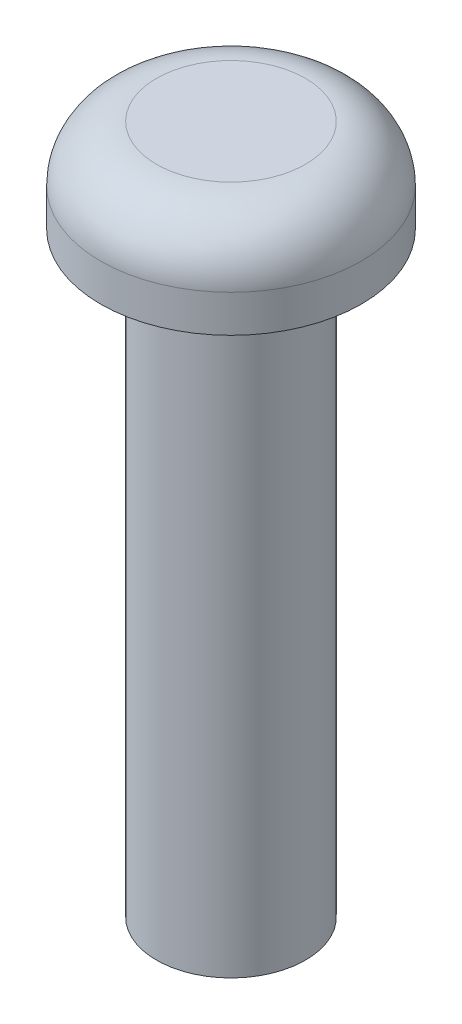
from build123d import *


with BuildPart() as part:
    # Sketch1 → Revolve1 (revolve)
    with BuildSketch(Plane.XY):
        with BuildLine():
            Line((2, 0), (3.5, 0))
            Line((3.5, 0), (3.5, 1))
            ThreePointArc((3.5, 1), (3.060660172, 2.060660172), (2, 2.5))
            Line((2, 2.5), (0, 2.5))
            Line((0, 2.5), (0, -16))
            Line((0, -16), (2, -16))
            Line((2, -16), (2, 0))
        make_face()
    revolve(axis=Axis((0, -16, 0), (0, 1, 0)))


solid = part.part
